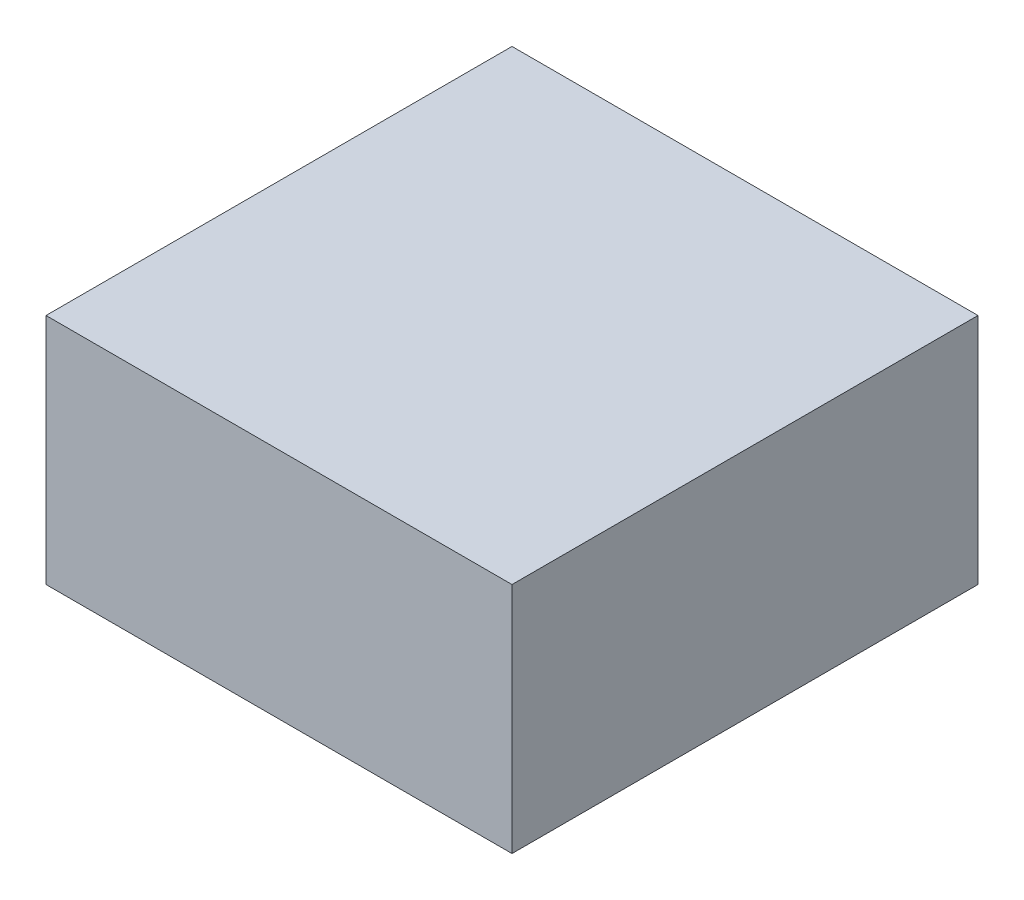
from build123d import *

# Parameters (mm, degrees)
ESBO_O1_W                = 10
ESBO_O1_H                = 5
RESSALTO_EXTRUS_O1_DEPTH = 10


with BuildPart() as part:
    # Esboço1 → Ressalto-extrusão1 (new body)
    with BuildSketch(Plane.XY):
        with Locations((0.032704715, -0.967336683)):
            Rectangle(ESBO_O1_W, ESBO_O1_H)
    extrude(amount=RESSALTO_EXTRUS_O1_DEPTH)


solid = part.part
